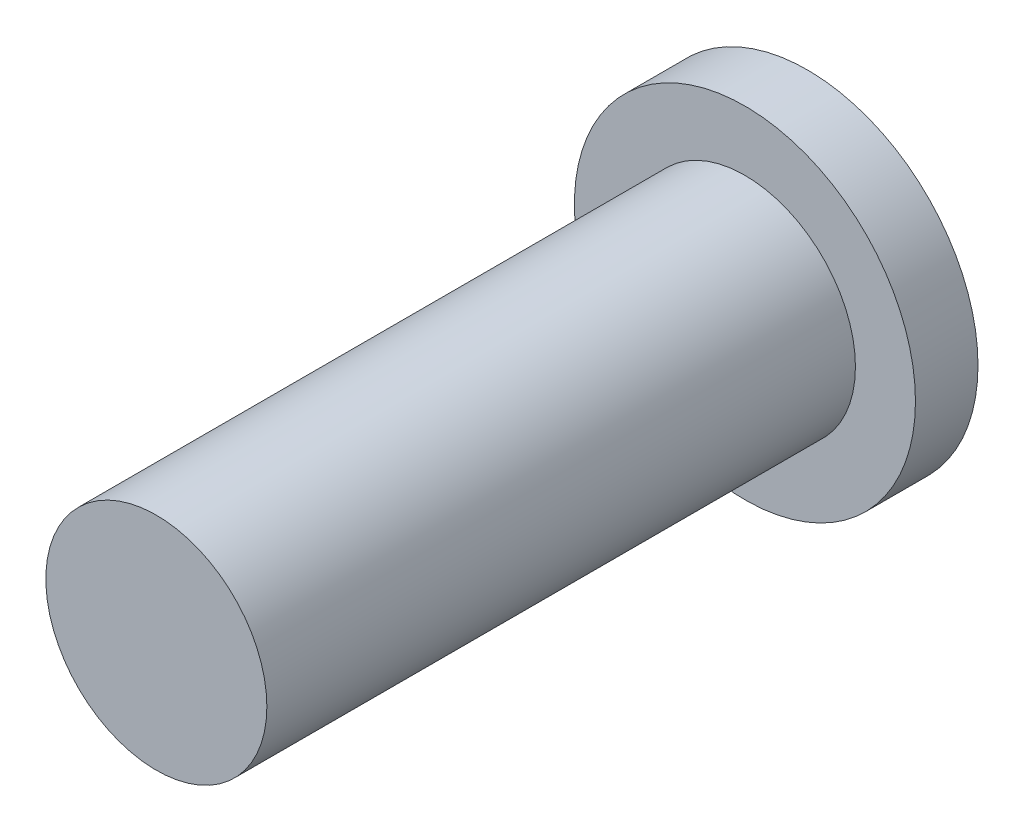
from build123d import *

# Parameters (mm, degrees)
SKETCH1_R           = 231.80521347
BOSS_EXTRUDE1_DEPTH = 85
SKETCH2_W           = 215.150125982
SKETCH2_H           = 209.680207524
BOSS_EXTRUDE3_DEPTH = 800
SKETCH3_R           = 35
CUT_EXTRUDE1_DEPTH  = 248
SKETCH4_R           = 150.212654375
BOSS_EXTRUDE5_DEPTH = 885


with BuildPart() as part:
    # Sketch1 → Boss-Extrude1 (new body)
    with BuildSketch(Plane.XY):
        Circle(SKETCH1_R)
    extrude(amount=BOSS_EXTRUDE1_DEPTH)

    # Sketch2 → Boss-Extrude3 (add)
    with BuildSketch(Plane.XY.offset(85)):
        Rectangle(SKETCH2_W, SKETCH2_H)
    extrude(amount=BOSS_EXTRUDE3_DEPTH)

    # Sketch3 → Cut-Extrude1 (cut)
    with BuildSketch(Plane(origin=(107.575062991, 0, 0), x_dir=(0, 0, -1), z_dir=(1, 0, 0))):
        with Locations((-795.184826294, 0)):
            Circle(SKETCH3_R)
    extrude(amount=-CUT_EXTRUDE1_DEPTH, mode=Mode.SUBTRACT)

    # Sketch4 → Boss-Extrude5 (add)
    with BuildSketch(Plane.XY.offset(885)):
        Circle(SKETCH4_R)
    extrude(amount=-BOSS_EXTRUDE5_DEPTH)


solid = part.part
